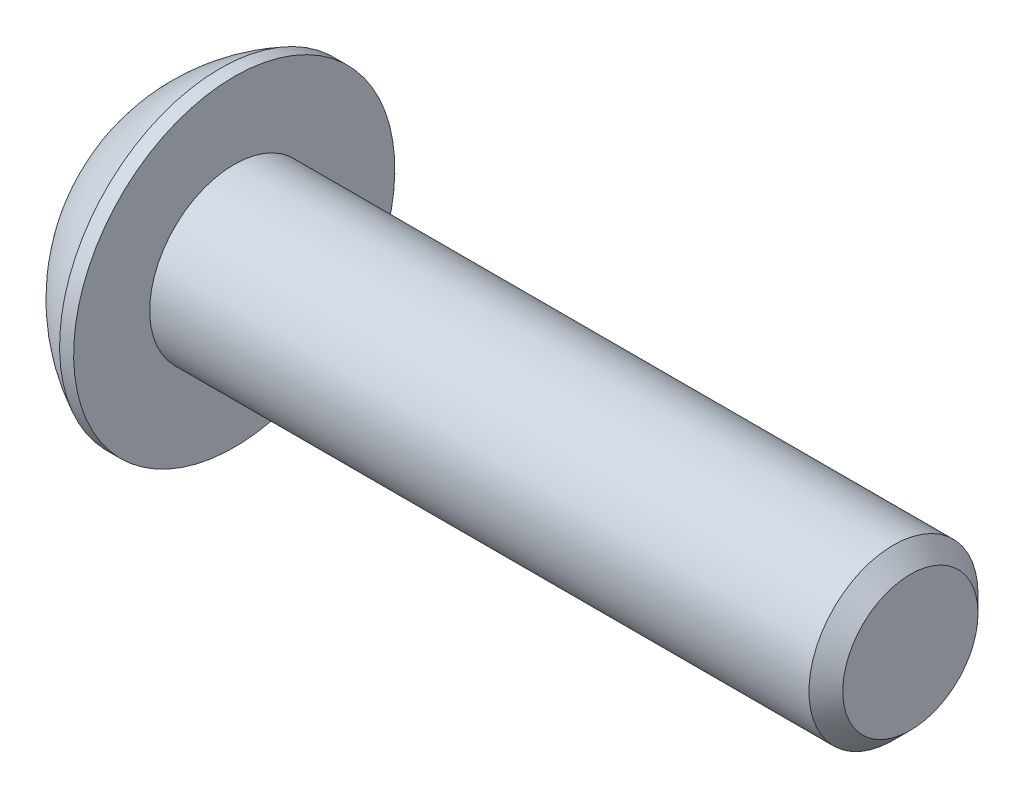
from build123d import *

# Parameters (mm, degrees)
SKETCH2_R           = 1.5
BOSS_EXTRUDE1_DEPTH = 12
CHAMFER1_SIZE       = 0.3
CUT_EXTRUDE1_DEPTH  = 1.2
SKETCH8_R           = 1.204700538
CUT_EXTRUDE2_DEPTH  = 1
CUT_EXTRUDE2_TAPER  = 45


with BuildPart() as part:
    # Sketch2 → Boss-Extrude1 (new body)
    with BuildSketch(Plane(origin=(0, 0, 0), x_dir=(0, 0, -1), z_dir=(1, 0, 0))):
        Circle(SKETCH2_R)
    extrude(amount=-BOSS_EXTRUDE1_DEPTH)

    # Chamfer1
    chamfer1_edges = [part.edges().sort_by_distance(p)[0] for p in [
        (0, 0, 1.5),
    ]]
    chamfer(chamfer1_edges, length=CHAMFER1_SIZE)

    # Sketch6 → Revolve1 (revolve)
    with BuildSketch(Plane.XY):
        with BuildLine():
            Line((-13.65, 0), (-13.65, 1.5))
            ThreePointArc((-13.65, 1.5), (-13.055944823, 2.284868705), (-12.25, 2.85))
            Line((-12.25, 2.85), (-12, 2.85))
            Line((-12, 2.85), (-12, 0))
            Line((-12, 0), (-13.65, 0))
        make_face()
    revolve(axis=Axis((-12, 0, 0), (-1, 0, 0)))

    # Sketch7 → Cut-Extrude1 (cut)
    with BuildSketch(Plane.ZY.offset(13.65)):
        Polygon((0, 1.154700538), (-1, 0.577350269), (-1, -0.577350269), (0, -1.154700538), (1, -0.577350269), (1, 0.577350269), align=None)
    extrude(amount=-CUT_EXTRUDE1_DEPTH, mode=Mode.SUBTRACT)

    # Sketch8 → Cut-Extrude2 (cut)
    with BuildSketch(Plane.ZY.offset(13.65)):
        Circle(SKETCH8_R)
    extrude(amount=-CUT_EXTRUDE2_DEPTH, taper=CUT_EXTRUDE2_TAPER, mode=Mode.SUBTRACT)


solid = part.part
